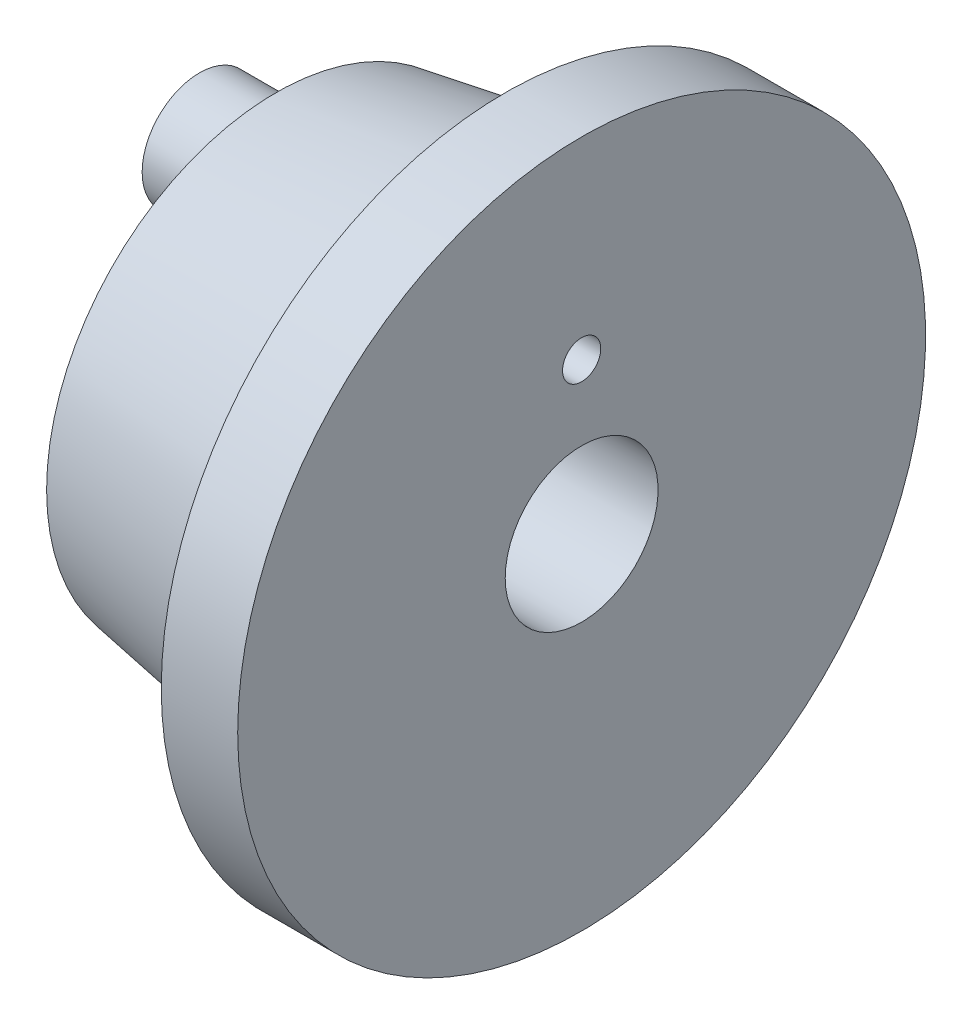
from build123d import *

# Parameters (mm, degrees)
SKETCH3_R           = 0.25
CUT_EXTRUDE1_DEPTH  = 4
SKETCH4_R           = 0.75
SKETCH4_R_2         = 0.25
BOSS_EXTRUDE1_DEPTH = 1


with BuildPart() as part:
    # Sketch1 → Revolve1 (revolve)
    with BuildSketch(Plane.XY):
        Polygon((0.927471423, 4.5), (1.927471423, 4.5), (1.927471423, 1), (-2.072528577, 1), (-2.072528577, 3), (0.927471423, 3.5), align=None)
    revolve(axis=Axis((-11.471189379, 0, 0), (1, 0, 0)))

    # Sketch3 → Cut-Extrude1 (cut)
    with BuildSketch(Plane.ZY.offset(2.072528577)):
        with Locations((0, 1.974515761)):
            Circle(SKETCH3_R)
    extrude(amount=-CUT_EXTRUDE1_DEPTH, mode=Mode.SUBTRACT)

    # Sketch4 → Boss-Extrude1 (add)
    with BuildSketch(Plane.ZY.offset(2.072528577)):
        with Locations((0, 1.974515761)):
            Circle(SKETCH4_R)
        with Locations((0, 1.974515761)):
            Circle(SKETCH4_R_2, mode=Mode.SUBTRACT)
    extrude(amount=BOSS_EXTRUDE1_DEPTH)


solid = part.part
